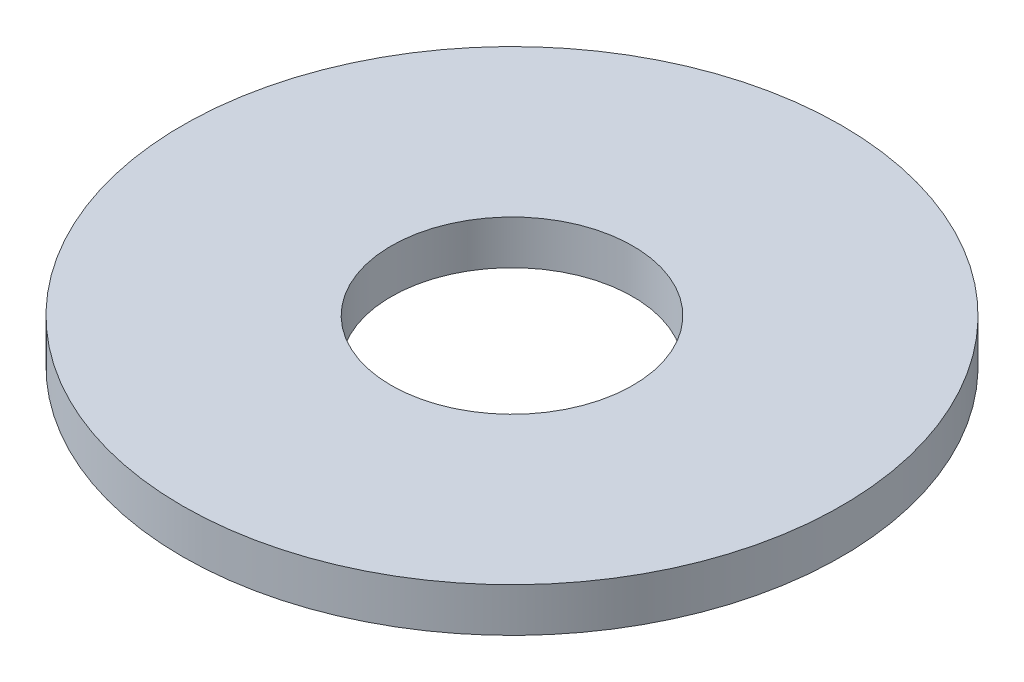
from build123d import *

# Parameters (mm, degrees)
ESQUISSE1_R      = 7.5
ESQUISSE1_R_2    = 2.75
EXTRUSION1_DEPTH = 1


with BuildPart() as part:
    # Esquisse1 → Extrusion1 (new body)
    with BuildSketch(Plane(origin=(0, 0, 0), x_dir=(1, 0, 0), z_dir=(0, 1, 0))):
        Circle(ESQUISSE1_R)
        Circle(ESQUISSE1_R_2, mode=Mode.SUBTRACT)
    extrude(amount=EXTRUSION1_DEPTH)


solid = part.part
